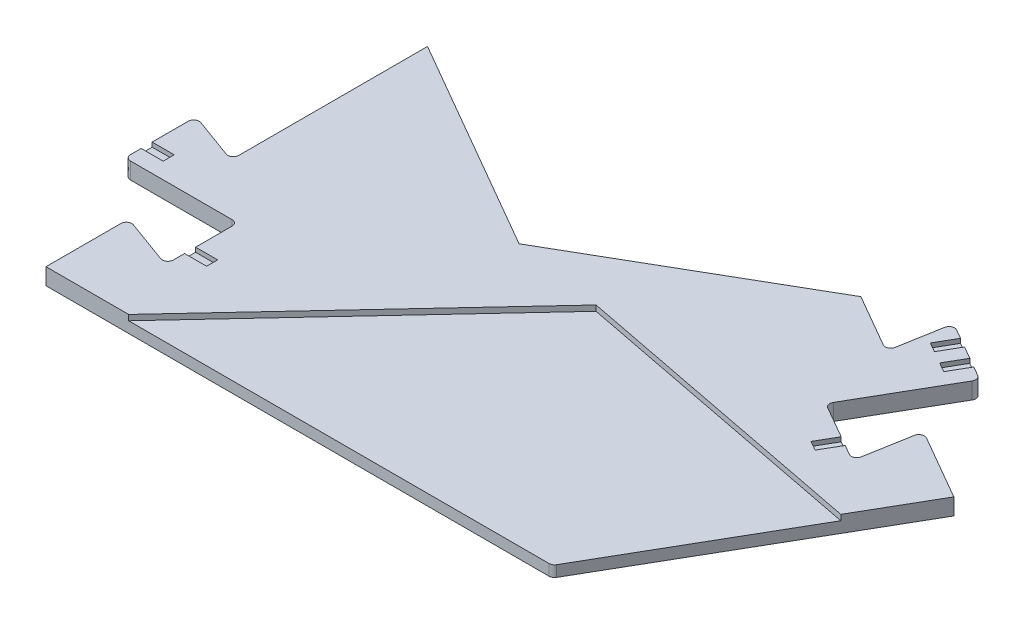
from build123d import *

# Parameters (mm, degrees)
P_IDAT_VYSUNUT_M1_DEPTH  = 3
P_IDAT_VYSUNUT_M2_DEPTH  = 2
ZAOBLIT1_R               = 1
ZAOBLIT2_R               = 1
SKICA2_W                 = 4
SKICA2_H                 = 2
ODEBRAT_VYSUNUT_M1_DEPTH = 0.8


with BuildPart() as part:
    # Skica1 → P_idat vysunut_m1 (new body)
    with BuildSketch(Plane(origin=(0, 0, 0), x_dir=(1, 0, 0), z_dir=(0, 1, 0))):
        Polygon((118.524103266, 46.190077074), (105.53372221, 53.690077074), (103.593400635, 42.685966604), (92.248467845, 49.235966604), (102.473720104, 66.946623035), (91.301992395, 73.396623035), (89.463213481, 62.968389614), (78.635106664, 69.22), (39.317553332, 46.52), (0, 69.22), (0, 33.55662508), (-9.950504516, 37.17831254), (-9.950504516, 24.27831254), (10.5, 24.27831254), (10.5, 11.17831254), (0, 15), (0, 0), (15, 0), (55.910618513, 43.889876884), (111.018549767, 33.190077074), align=None)
    extrude(amount=P_IDAT_VYSUNUT_M1_DEPTH)

    # Skica1_3 → P_idat vysunut_m2 (add)
    with BuildSketch(Plane(origin=(0, 0, 0), x_dir=(1, 0, 0), z_dir=(0, 1, 0))):
        Polygon((91.856249834, 0), (111.018549767, 33.190077074), (55.910618513, 43.889876884), (15, 0), align=None)
    extrude(amount=P_IDAT_VYSUNUT_M2_DEPTH)

    # Zaoblit1
    zaoblit1_edges = [part.edges().sort_by_distance(p)[0] for p in [
        (102.473720104, 1.5, -66.946623035),
        (92.248467845, 1.5, -49.235966604),
        (103.593400635, 1.5, -42.685966604),
        (105.53372221, 1.5, -53.690077074),
        (0, 1.5, -15),
        (10.5, 1.5, -11.17831254),
        (10.5, 1.5, -24.27831254),
        (-9.950504516, 1.5, -24.27831254),
        (-9.950504516, 1.5, -37.17831254),
        (0, 1.5, -33.55662508),
        (89.463213481, 1.5, -62.968389614),
        (91.301992395, 1.5, -73.396623035),
    ]]
    fillet(zaoblit1_edges, radius=ZAOBLIT1_R)

    # Zaoblit2
    zaoblit2_edges = [part.edges().sort_by_distance(p)[0] for p in [
        (91.856249834, 1, 0),
    ]]
    fillet(zaoblit2_edges, radius=ZAOBLIT2_R)

    # Skica2 → Odebrat vysunut_m1 (cut)
    with BuildSketch(Plane(origin=(0, 3, 0), x_dir=(1, 0, 0), z_dir=(0, 1, 0))):
        with Locations((12.5, 15.642386544)):
            Rectangle(SKICA2_W, SKICA2_H)
        with Locations((-7.950504516, 28.214238537)):
            Rectangle(SKICA2_W, SKICA2_H)
        Polygon((98.86137374, 45.418003606), (96.86137374, 41.953901991), (98.593424548, 40.953901991), (100.593424548, 44.418003606), align=None)
        Polygon((98.199082799, 69.414586034), (96.199082799, 65.950484418), (97.931133607, 64.950484418), (99.931133607, 68.414586034), align=None)
        Polygon((92.215365942, 68.250484418), (94.215365942, 71.714586034), (95.947416749, 70.714586034), (93.947416749, 67.250484418), align=None)
    extrude(amount=-ODEBRAT_VYSUNUT_M1_DEPTH, mode=Mode.SUBTRACT)


solid = part.part
